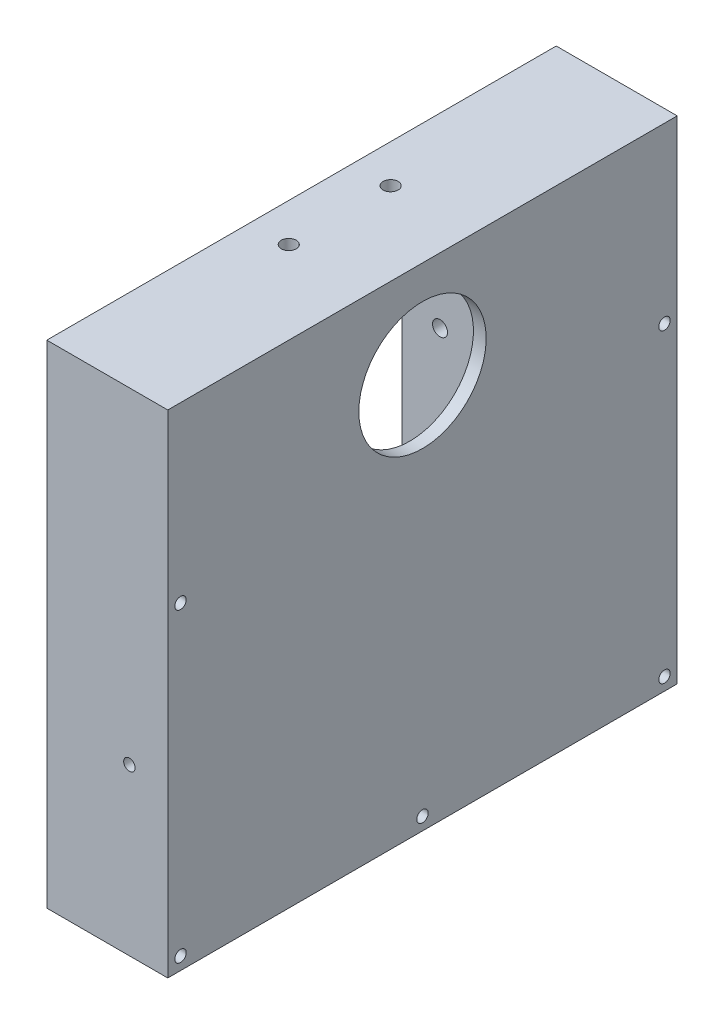
from build123d import *

# Parameters (mm, degrees)
SKETCH_1_W                    = 100
SKETCH_1_H                    = 80
EXTRUDE_1_DEPTH               = 19
SKETCH_2_W                    = 72
SKETCH_2_H                    = 92
CUT_EXTRUDE_1_DEPTH           = 17
SKETCH_3_W                    = 36.5
SKETCH_3_H                    = 54.5
EXTRUDE_2_DEPTH               = 17
SKETCH_4_W                    = 31.5
SKETCH_4_H                    = 49.5
CUT_EXTRUDE_2_DEPTH           = 17
HOLE_WIZARD_20_0_20_1_D       = 20
HOLE_WIZARD_20_0_20_1_DEPTH   = 2
HOLE_WIZARD_1_8_1_8_1_D       = 1.8
HOLE_WIZARD_1_8_1_8_2_D       = 1.8
HOLE_WIZARD_1_8_1_8_2_DEPTH   = 4
HOLE_WIZARD_1_8_1_8_3_D       = 1.8
HOLE_WIZARD_1_8_1_8_3_DEPTH   = 4
HOLE_WIZARD_2_35_2_35_1_D     = 2.35
HOLE_WIZARD_2_35_2_35_1_DEPTH = 2.5
HOLE_WIZARD_2_35_2_35_2_D     = 2.35
HOLE_WIZARD_2_35_2_35_2_DEPTH = 2.5
HOLE_WIZARD_2_35_2_35_3_D     = 2.35
HOLE_WIZARD_2_35_2_35_3_DEPTH = 2.5
HOLE_WIZARD_2_35_2_35_4_D     = 2.35
HOLE_WIZARD_2_35_2_35_4_DEPTH = 2.5
SKETCH_22_W                   = 13
SKETCH_22_H                   = 36.5
CUT_EXTRUDE_5_DEPTH           = 10
SKETCH_23_W                   = 80
SKETCH_23_H                   = 22.75
CUT_EXTRUDE_6_DEPTH           = 19
SKETCH_24_W                   = 17
SKETCH_24_H                   = 17.75
EXTRUDE_3_DEPTH               = 4
SKETCH_25_R                   = 0.9
EXTRUDE_4_DEPTH               = 4
EXTRUDE_START                 = -4
SKETCH_26_R                   = 0.9
EXTRUDE_5_DEPTH               = 4


with BuildPart() as part:
    # 스케치1 → 보스-돌출1 (new body)
    with BuildSketch(Plane(origin=(0, 0, 0), x_dir=(0, -1, 0), z_dir=(-1, 0, 0))):
        with Locations((-23.25, -14.25)):
            Rectangle(SKETCH_1_W, SKETCH_1_H)
    extrude(amount=-EXTRUDE_1_DEPTH)

    # 스케치2 → 컷-돌출1 (cut)
    with BuildSketch(Plane.ZY):
        with Locations((-14.25, 23.25)):
            Rectangle(SKETCH_2_W, SKETCH_2_H)
    extrude(amount=-CUT_EXTRUDE_1_DEPTH, mode=Mode.SUBTRACT)

    # 스케치3 → 보스-돌출2 (add)
    with BuildSketch(Plane.ZY.offset(-17)):
        with Locations((-14.25, 23.25)):
            Rectangle(SKETCH_3_W, SKETCH_3_H)
    extrude(amount=EXTRUDE_2_DEPTH)

    # 스케치4 → 컷-돌출2 (cut)
    with BuildSketch(Plane.ZY):
        with Locations((-14.25, 23.25)):
            Rectangle(SKETCH_4_W, SKETCH_4_H)
    extrude(amount=-CUT_EXTRUDE_2_DEPTH, mode=Mode.SUBTRACT)

    # Ø20.0 (20) 지름 구멍1
    with Locations(Plane.ZY.offset(-17)):
        with Locations((-14.25, 35.25)):
            Hole(HOLE_WIZARD_20_0_20_1_D / 2, depth=HOLE_WIZARD_20_0_20_1_DEPTH)

    # Ø1.8 (1.8) 지름 구멍1 (through all)
    with Locations(Plane.ZY):
        with Locations((-52.25, 71.25), (-14.25, 71.25), (23.75, 71.25), (23.75, -24.75), (-14.25, -24.75), (-52.25, -24.75), (-52.25, 23.25), (23.75, 23.25)):
            Hole(HOLE_WIZARD_1_8_1_8_1_D / 2)

    # Ø1.8 (1.8) 지름 구멍2
    with Locations(Plane.XY.offset(-50.25)):
        with Locations((12.975, -0.75), (12.975, 47.25)):
            Hole(HOLE_WIZARD_1_8_1_8_2_D / 2, depth=HOLE_WIZARD_1_8_1_8_2_DEPTH)

    # Ø1.8 (1.8) 지름 구멍3
    with Locations(Plane(origin=(0, 0, 21.75), x_dir=(-1, 0, 0), z_dir=(0, 0, -1))):
        with Locations((-12.975, -0.75), (-12.975, 47.25)):
            Hole(HOLE_WIZARD_1_8_1_8_3_D / 2, depth=HOLE_WIZARD_1_8_1_8_3_DEPTH)

    # Ø2.35 (2.35) 지름 구멍1
    with Locations(Plane(origin=(0, -1.5, 0), x_dir=(1, 0, 0), z_dir=(0, 1, 0))):
        with Locations((6, 6.25), (6, 22.25)):
            Hole(HOLE_WIZARD_2_35_2_35_1_D / 2, depth=HOLE_WIZARD_2_35_2_35_1_DEPTH)

    # Ø2.35 (2.35) 지름 구멍2
    with Locations(Plane.XY.offset(-30)):
        with Locations((6, 27.25), (6, 3.25)):
            Hole(HOLE_WIZARD_2_35_2_35_2_D / 2, depth=HOLE_WIZARD_2_35_2_35_2_DEPTH)

    # Ø2.35 (2.35) 지름 구멍3
    with Locations(Plane(origin=(0, 48, 0), x_dir=(-1, 0, 0), z_dir=(0, -1, 0))):
        with Locations((-6, 6.25), (-6, 22.25)):
            Hole(HOLE_WIZARD_2_35_2_35_3_D / 2, depth=HOLE_WIZARD_2_35_2_35_3_DEPTH)

    # Ø2.35 (2.35) 지름 구멍4
    with Locations(Plane(origin=(0, 0, 1.5), x_dir=(-1, 0, 0), z_dir=(0, 0, -1))):
        with Locations((-6, 27.25), (-6, 3.25)):
            Hole(HOLE_WIZARD_2_35_2_35_4_D / 2, depth=HOLE_WIZARD_2_35_2_35_4_DEPTH)

    # 스케치22 → 컷-돌출5 (cut)
    with BuildSketch(Plane.XZ.offset(26.75)):
        with Locations((6.5, -14.25)):
            Rectangle(SKETCH_22_W, SKETCH_22_H)
    extrude(amount=-CUT_EXTRUDE_5_DEPTH, mode=Mode.SUBTRACT)

    # 스케치23 → 컷-돌출6 (cut)
    with BuildSketch(Plane.ZY):
        with Locations((-14.25, 61.875)):
            Rectangle(SKETCH_23_W, SKETCH_23_H)
    extrude(amount=-CUT_EXTRUDE_6_DEPTH, mode=Mode.SUBTRACT)

    # 스케치24 → 보스-돌출3 (add)
    with BuildSketch(Plane(origin=(0, 50.5, 0), x_dir=(1, 0, 0), z_dir=(0, 1, 0))):
        with Locations((8.5, -12.875)):
            Rectangle(SKETCH_24_W, SKETCH_24_H)
        with Locations((8.5, 41.375)):
            Rectangle(SKETCH_24_W, SKETCH_24_H)
    extrude(amount=-EXTRUDE_3_DEPTH)

    # 스케치25 → 보스-돌출4 (add)
    with BuildSketch(Plane.XY.offset(25.75)):
        with Locations((12.975, 47.25)):
            Circle(SKETCH_25_R)
    extrude(amount=-EXTRUDE_4_DEPTH)

    # 스케치26 → 보스-돌출5 (add)
    with BuildSketch(Plane(origin=(0, 0, -54.25), x_dir=(-1, 0, 0), z_dir=(0, 0, -1)).offset(EXTRUDE_START)):
        with Locations((-12.975, 47.25)):
            Circle(SKETCH_26_R)
    extrude(amount=EXTRUDE_5_DEPTH)


solid = part.part
